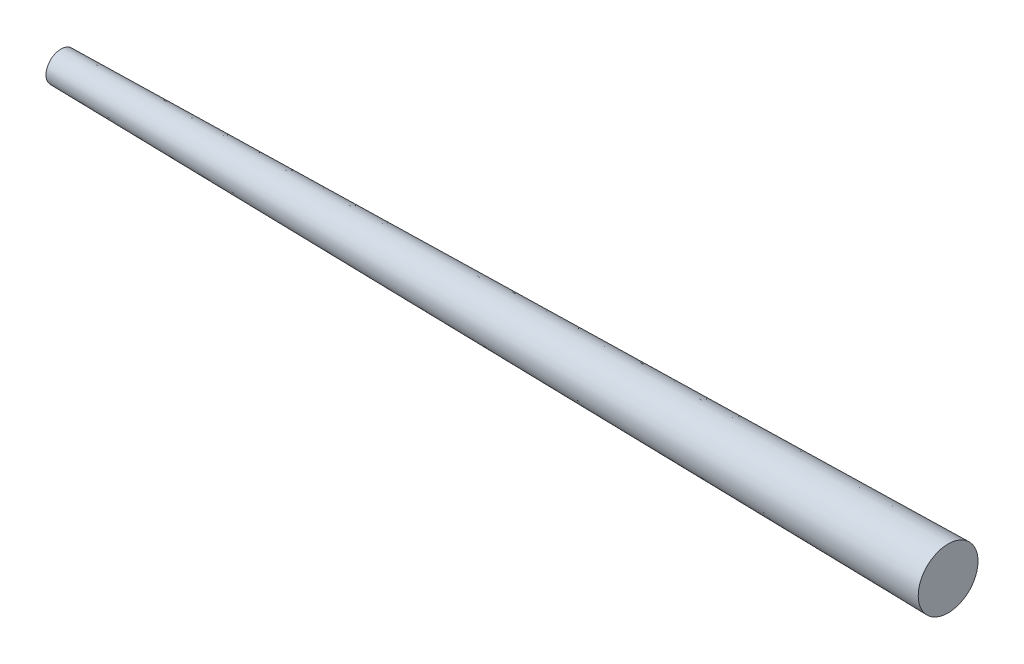
from build123d import *


with BuildPart() as part:
    # Skizze1 → Rotation1 (revolve)
    with BuildSketch(Plane.XY):
        Polygon((-5.563444822, 0), (-5.563444822, 1.5), (83.436555178, 3), (83.436555178, 0), align=None)
    revolve(axis=Axis((83.436555178, 0, 0), (-1, 0, 0)))


solid = part.part
